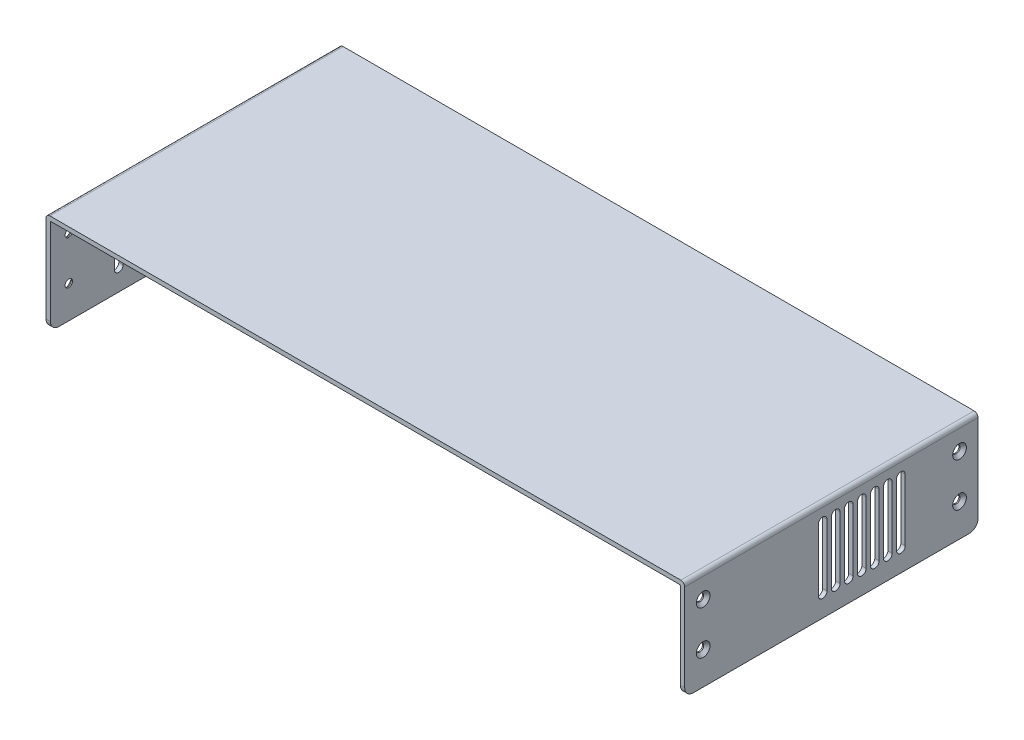
from build123d import *

# Parameters (mm, degrees)
BOSS_EXTRUDE1_DEPTH                             = 135
CSK_FOR_M3_FLAT_HEAD_MACHINE_SCREW1_D           = 3.4
CSK_FOR_M3_FLAT_HEAD_MACHINE_SCREW1_DEPTH       = 5
CSK_FOR_M3_FLAT_HEAD_MACHINE_SCREW1_CSINK_D     = 6.3
CSK_FOR_M3_FLAT_HEAD_MACHINE_SCREW1_CSINK_ANGLE = 90
CSK_FOR_M3_FLAT_HEAD_MACHINE_SCREW1_TIP         = 1.021463052
CSK_FOR_M3_FLAT_HEAD_MACHINE_SCREW2_D           = 3.4
CSK_FOR_M3_FLAT_HEAD_MACHINE_SCREW2_DEPTH       = 5
CSK_FOR_M3_FLAT_HEAD_MACHINE_SCREW2_CSINK_D     = 6.3
CSK_FOR_M3_FLAT_HEAD_MACHINE_SCREW2_CSINK_ANGLE = 90
CSK_FOR_M3_FLAT_HEAD_MACHINE_SCREW2_TIP         = 1.021463052
FILLET1_R                                       = 4
CUT_EXTRUDE1_DEPTH                              = 10
LPATTERN1_COUNT                                 = 13
LPATTERN1_PITCH                                 = 6
CUT_EXTRUDE2_DEPTH                              = 10
LPATTERN2_COUNT                                 = 7
LPATTERN2_PITCH                                 = 6


with BuildPart() as part:
    # Sketch1 → Boss-Extrude1 (new body)
    with BuildSketch(Plane.XY):
        with BuildLine():
            Line((0, 0), (-2, 0))
            Line((-2, 0), (-2, 44.2))
            ThreePointArc((-2, 44.2), (-1.472792206, 45.472792206), (-0.2, 46))
            Line((-0.2, 46), (290.2, 46))
            ThreePointArc((290.2, 46), (291.472792206, 45.472792206), (292, 44.2))
            Line((292, 44.2), (292, 0))
            Line((292, 0), (290, 0))
            Line((290, 0), (290, 43.5))
            ThreePointArc((290, 43.5), (289.853553391, 43.853553391), (289.5, 44))
            Line((289.5, 44), (0.5, 44))
            ThreePointArc((0.5, 44), (0.146446609, 43.853553391), (0, 43.5))
            Line((0, 43.5), (0, 0))
        make_face()
    extrude(amount=BOSS_EXTRUDE1_DEPTH)

    # CSK for M3 Flat Head Machine Screw1
    with Locations(Plane.ZY.offset(2)):
        with Locations((8.5, 35), (8.5, 15), (126.5, 35), (126.5, 15)):
            CounterSinkHole(CSK_FOR_M3_FLAT_HEAD_MACHINE_SCREW1_D / 2, CSK_FOR_M3_FLAT_HEAD_MACHINE_SCREW1_CSINK_D / 2, depth=CSK_FOR_M3_FLAT_HEAD_MACHINE_SCREW1_DEPTH, counter_sink_angle=CSK_FOR_M3_FLAT_HEAD_MACHINE_SCREW1_CSINK_ANGLE)
            with Locations((0, 0, -(CSK_FOR_M3_FLAT_HEAD_MACHINE_SCREW1_DEPTH + CSK_FOR_M3_FLAT_HEAD_MACHINE_SCREW1_TIP / 2))):  # 118° drill point
                Cone(0, CSK_FOR_M3_FLAT_HEAD_MACHINE_SCREW1_D / 2, CSK_FOR_M3_FLAT_HEAD_MACHINE_SCREW1_TIP, mode=Mode.SUBTRACT)

    # CSK for M3 Flat Head Machine Screw2
    with Locations(Plane(origin=(292, 0, 0), x_dir=(0, 0, -1), z_dir=(1, 0, 0))):
        with Locations((-126.5, 35), (-126.5, 15), (-8.5, 35), (-8.5, 15)):
            CounterSinkHole(CSK_FOR_M3_FLAT_HEAD_MACHINE_SCREW2_D / 2, CSK_FOR_M3_FLAT_HEAD_MACHINE_SCREW2_CSINK_D / 2, depth=CSK_FOR_M3_FLAT_HEAD_MACHINE_SCREW2_DEPTH, counter_sink_angle=CSK_FOR_M3_FLAT_HEAD_MACHINE_SCREW2_CSINK_ANGLE)
            with Locations((0, 0, -(CSK_FOR_M3_FLAT_HEAD_MACHINE_SCREW2_DEPTH + CSK_FOR_M3_FLAT_HEAD_MACHINE_SCREW2_TIP / 2))):  # 118° drill point
                Cone(0, CSK_FOR_M3_FLAT_HEAD_MACHINE_SCREW2_D / 2, CSK_FOR_M3_FLAT_HEAD_MACHINE_SCREW2_TIP, mode=Mode.SUBTRACT)

    # Fillet1
    fillet1_edges = [part.edges().sort_by_distance(p)[0] for p in [
        (-1, 0, 0),
        (291, 0, 0),
        (291, 0, 135),
        (-1, 0, 135),
    ]]
    fillet(fillet1_edges, radius=FILLET1_R)

    # Sketch6 → Cut-Extrude1 (cut)
    with BuildSketch(Plane(origin=(-2, 0, 0), x_dir=(0, 0, -1), z_dir=(1, 0, 0))):
        with BuildLine():
            Line((-101.5, 38.35), (-101.5, 9.85))
            ThreePointArc((-101.5, 9.85), (-103.5, 7.85), (-105.5, 9.85))
            Line((-105.5, 9.85), (-105.5, 38.35))
            ThreePointArc((-105.5, 38.35), (-103.5, 40.35), (-101.5, 38.35))
        make_face()
    cut_extrude1 = extrude(amount=CUT_EXTRUDE1_DEPTH, mode=Mode.SUBTRACT)

    # LPattern1: Cut-Extrude1 ×13
    with Locations(*[(0, 0, -i * LPATTERN1_PITCH) for i in range(1, LPATTERN1_COUNT)]):
        add(cut_extrude1, mode=Mode.SUBTRACT)

    # Sketch7 → Cut-Extrude2 (cut)
    with BuildSketch(Plane(origin=(292, 0, 0), x_dir=(0, 0, -1), z_dir=(1, 0, 0))):
        with BuildLine():
            Line((-33.5, 38.35), (-33.5, 9.85))
            ThreePointArc((-33.5, 9.85), (-35.5, 7.85), (-37.5, 9.85))
            Line((-37.5, 9.85), (-37.5, 38.35))
            ThreePointArc((-37.5, 38.35), (-35.5, 40.35), (-33.5, 38.35))
        make_face()
    cut_extrude2 = extrude(amount=-CUT_EXTRUDE2_DEPTH, mode=Mode.SUBTRACT)

    # LPattern2: Cut-Extrude2 ×7
    with Locations(*[(0, 0, i * LPATTERN2_PITCH) for i in range(1, LPATTERN2_COUNT)]):
        add(cut_extrude2, mode=Mode.SUBTRACT)


solid = part.part
